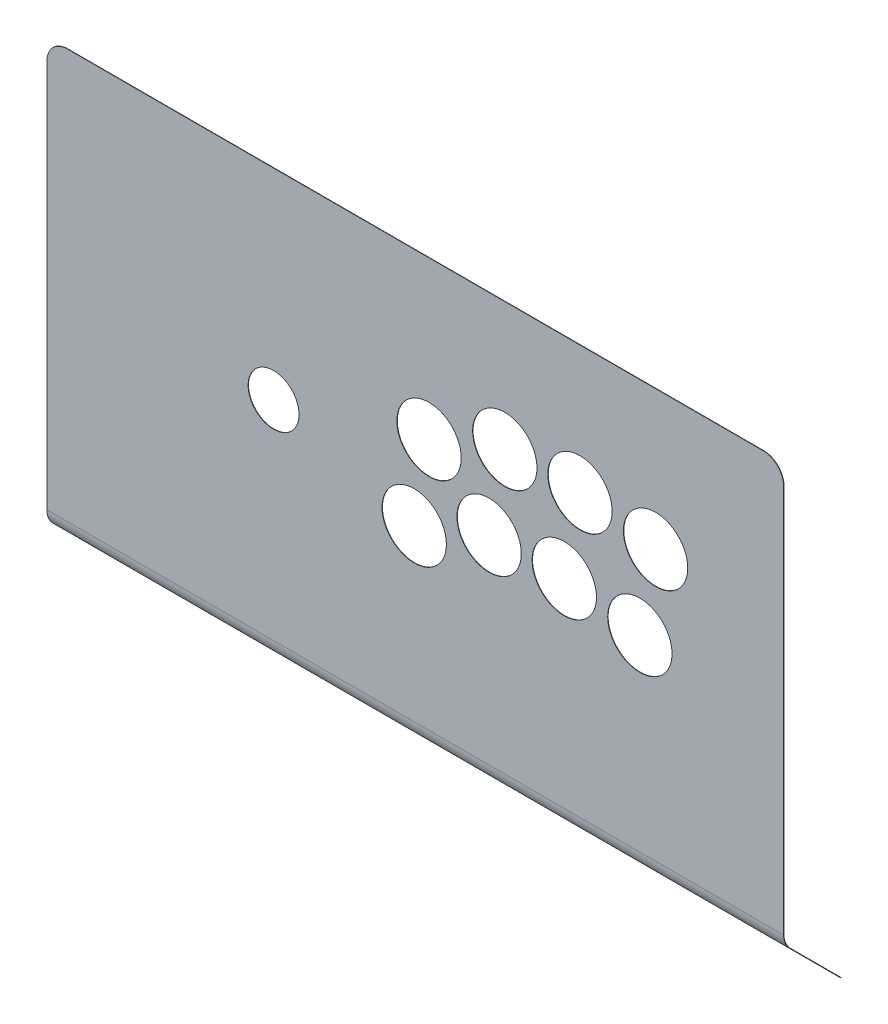
from build123d import *

# Parameters (mm, degrees)
SALIENTE_EXTRUIR1_DEPTH = 180
CORTAR_EXTRUIR1_DEPTH   = 33.901365266
REDONDEO1_R             = 10


with BuildPart() as part:
    # Croquis1 → Saliente-Extruir1 (new body, symmetric)
    with BuildSketch(Plane(origin=(0, 0, 0), x_dir=(0, 0, -1), z_dir=(1, 0, 0))):
        with BuildLine():
            Line((-0.1, 0), (-0.1, -200))
            ThreePointArc((-0.1, -200), (0.668816722, -203.865102667), (2.85822151, -207.14177849))
            Line((2.85822151, -207.14177849), (32.65994391, -236.94350089))
            Line((32.65994391, -236.94350089), (32.801365266, -236.802079534))
            Line((32.801365266, -236.802079534), (2.999642866, -207.000357134))
            ThreePointArc((2.999642866, -207.000357134), (0.853592628, -203.78856598), (0.1, -200))
            Line((0.1, -200), (0.1, 0))
            Line((0.1, 0), (-0.1, 0))
        make_face()
    extrude(amount=SALIENTE_EXTRUIR1_DEPTH, both=True)

    # Croquis3 → Cortar-Extruir1 (cut, through all)
    with BuildSketch(Plane.XY.offset(0.1)):
        with BuildLine():
            add(Edge.make_bspline(
                [(-56.818714387, -98.117897598), (-56.818714387, -91.25310519), (-62.383577946, -85.688592196), (-69.248335297, -85.688592196)],
                knots=[0, 0, 0, 0, 1, 1, 1, 1], degree=3))
            add(Edge.make_bspline(
                [(-69.248335297, -85.688592196), (-76.113123116, -85.688592196), (-81.678337379, -91.25310519), (-81.678337379, -98.117897598)],
                knots=[1, 1, 1, 1, 2, 2, 2, 2], degree=3))
            add(Edge.make_bspline(
                [(-81.678337379, -98.117897598), (-81.678337379, -104.982654949), (-76.113123116, -110.547167943), (-69.248335297, -110.547167943)],
                knots=[2, 2, 2, 2, 3, 3, 3, 3], degree=3))
            add(Edge.make_bspline(
                [(-69.248335297, -110.547167943), (-62.383577946, -110.547167943), (-56.818714387, -104.982654949), (-56.818714387, -98.117897598)],
                knots=[3, 3, 3, 3, 4, 4, 4, 4], degree=3))
        make_face()
        with BuildLine():
            add(Edge.make_bspline(
                [(59.462640026, -62.574601525), (59.462640026, -53.897424834), (52.429085786, -46.863555086), (43.751601027, -46.863555086)],
                knots=[0, 0, 0, 0, 1, 1, 1, 1], degree=3))
            add(Edge.make_bspline(
                [(43.751601027, -46.863555086), (35.074774682, -46.863555086), (28.040196583, -53.897424834), (28.040196583, -62.574601525)],
                knots=[1, 1, 1, 1, 2, 2, 2, 2], degree=3))
            add(Edge.make_bspline(
                [(28.040196583, -62.574601525), (28.040196583, -71.25174316), (35.074774682, -78.285647964), (43.751601027, -78.285647964)],
                knots=[2, 2, 2, 2, 3, 3, 3, 3], degree=3))
            add(Edge.make_bspline(
                [(43.751601027, -78.285647964), (52.429085786, -78.285647964), (59.462640026, -71.25174316), (59.462640026, -62.574601525)],
                knots=[3, 3, 3, 3, 4, 4, 4, 4], degree=3))
        make_face()
        with BuildLine():
            add(Edge.make_bspline(
                [(96.199012837, -62.574601525), (96.199012837, -53.897424834), (89.165108032, -46.863555086), (80.487974766, -46.863555086)],
                knots=[0, 0, 0, 0, 1, 1, 1, 1], degree=3))
            add(Edge.make_bspline(
                [(80.487974766, -46.863555086), (71.811498985, -46.863555086), (64.777235467, -53.897424834), (64.777235467, -62.574601525)],
                knots=[1, 1, 1, 1, 2, 2, 2, 2], degree=3))
            add(Edge.make_bspline(
                [(64.777235467, -62.574601525), (64.777235467, -71.25174316), (71.811498985, -78.285647964), (80.487974766, -78.285647964)],
                knots=[2, 2, 2, 2, 3, 3, 3, 3], degree=3))
            add(Edge.make_bspline(
                [(80.487974766, -78.285647964), (89.165108032, -78.285647964), (96.199012837, -71.25174316), (96.199012837, -62.574601525)],
                knots=[3, 3, 3, 3, 4, 4, 4, 4], degree=3))
        make_face()
        with BuildLine():
            add(Edge.make_bspline(
                [(133.13290348, -68.068616053), (133.13290348, -59.391439362), (126.099033555, -52.357569614), (117.421856645, -52.357569614)],
                knots=[0, 0, 0, 0, 1, 1, 1, 1], degree=3))
            add(Edge.make_bspline(
                [(117.421856645, -52.357569614), (108.744714791, -52.357569614), (101.710809809, -59.391439362), (101.710809809, -68.068616053)],
                knots=[1, 1, 1, 1, 2, 2, 2, 2], degree=3))
            add(Edge.make_bspline(
                [(101.710809809, -68.068616053), (101.710809809, -76.745753799), (108.744714791, -83.779662492), (117.421856645, -83.779662492)],
                knots=[2, 2, 2, 2, 3, 3, 3, 3], degree=3))
            add(Edge.make_bspline(
                [(117.421856645, -83.779662492), (126.099033555, -83.779662492), (133.13290348, -76.745753799), (133.13290348, -68.068616053)],
                knots=[3, 3, 3, 3, 4, 4, 4, 4], degree=3))
        make_face()
        with BuildLine():
            add(Edge.make_bspline(
                [(125.465002278, -108.226079357), (125.465002278, -99.548201536), (118.431097296, -92.514331788), (109.753955442, -92.514331788)],
                knots=[0, 0, 0, 0, 1, 1, 1, 1], degree=3))
            add(Edge.make_bspline(
                [(109.753955442, -92.514331788), (101.076778532, -92.514331788), (94.042908606, -99.548201536), (94.042908606, -108.226079357)],
                knots=[1, 1, 1, 1, 2, 2, 2, 2], degree=3))
            add(Edge.make_bspline(
                [(94.042908606, -108.226079357), (94.042908606, -116.902554918), (101.076778532, -123.936424666), (109.753955442, -123.936424666)],
                knots=[2, 2, 2, 2, 3, 3, 3, 3], degree=3))
            add(Edge.make_bspline(
                [(109.753955442, -123.936424666), (118.431097296, -123.936424666), (125.465002278, -116.902554918), (125.465002278, -108.226079357)],
                knots=[3, 3, 3, 3, 4, 4, 4, 4], degree=3))
        make_face()
        with BuildLine():
            add(Edge.make_bspline(
                [(88.532443974, -102.730697627), (88.532443974, -94.053520936), (81.498223661, -87.019651188), (72.821397535, -87.019651188)],
                knots=[0, 0, 0, 0, 1, 1, 1, 1], degree=3))
            add(Edge.make_bspline(
                [(72.821397535, -87.019651188), (64.143905336, -87.019651188), (57.110000531, -94.053520936), (57.110000531, -102.730697627)],
                knots=[1, 1, 1, 1, 2, 2, 2, 2], degree=3))
            add(Edge.make_bspline(
                [(57.110000531, -102.730697627), (57.110000531, -111.407836338), (64.143905336, -118.441744066), (72.821397535, -118.441744066)],
                knots=[2, 2, 2, 2, 3, 3, 3, 3], degree=3))
            add(Edge.make_bspline(
                [(72.821397535, -118.441744066), (81.498223661, -118.441744066), (88.532443974, -111.407836338), (88.532443974, -102.730697627)],
                knots=[3, 3, 3, 3, 4, 4, 4, 4], degree=3))
        make_face()
        with BuildLine():
            add(Edge.make_bspline(
                [(51.794703961, -102.730697627), (51.794703961, -94.053520936), (44.761184778, -87.019651188), (36.083657522, -87.019651188)],
                knots=[0, 0, 0, 0, 1, 1, 1, 1], degree=3))
            add(Edge.make_bspline(
                [(36.083657522, -87.019651188), (27.406831395, -87.019651188), (20.372260518, -94.053520936), (20.372260518, -102.730697627)],
                knots=[1, 1, 1, 1, 2, 2, 2, 2], degree=3))
            add(Edge.make_bspline(
                [(20.372260518, -102.730697627), (20.372260518, -111.407836338), (27.406831395, -118.441744066), (36.083657522, -118.441744066)],
                knots=[2, 2, 2, 2, 3, 3, 3, 3], degree=3))
            add(Edge.make_bspline(
                [(36.083657522, -118.441744066), (44.761184778, -118.441744066), (51.794703961, -111.407836338), (51.794703961, -102.730697627)],
                knots=[3, 3, 3, 3, 4, 4, 4, 4], degree=3))
        make_face()
        with BuildLine():
            add(Edge.make_bspline(
                [(15.193929476, -117.043586996), (15.193929476, -108.366410305), (8.160024671, -101.332540557), (-0.516450891, -101.332540557)],
                knots=[0, 0, 0, 0, 1, 1, 1, 1], degree=3))
            add(Edge.make_bspline(
                [(-0.516450891, -101.332540557), (-9.194293654, -101.332540557), (-16.228198459, -108.366410305), (-16.228198459, -117.043586996)],
                knots=[1, 1, 1, 1, 2, 2, 2, 2], degree=3))
            add(Edge.make_bspline(
                [(-16.228198459, -117.043586996), (-16.228198459, -125.720062558), (-9.194293654, -132.753932306), (-0.516450891, -132.753932306)],
                knots=[2, 2, 2, 2, 3, 3, 3, 3], degree=3))
            add(Edge.make_bspline(
                [(-0.516450891, -132.753932306), (8.160024671, -132.753932306), (15.193929476, -125.720062558), (15.193929476, -117.043586996)],
                knots=[3, 3, 3, 3, 4, 4, 4, 4], degree=3))
        make_face()
        with BuildLine():
            add(Edge.make_bspline(
                [(22.44553494, -76.886824822), (22.44553494, -68.21034926), (15.4119807, -61.17577419), (6.735154573, -61.17577419)],
                knots=[0, 0, 0, 0, 1, 1, 1, 1], degree=3))
            add(Edge.make_bspline(
                [(6.735154573, -61.17577419), (-1.941987061, -61.17577419), (-8.976207374, -68.21034926), (-8.976207374, -76.886824822)],
                knots=[1, 1, 1, 1, 2, 2, 2, 2], degree=3))
            add(Edge.make_bspline(
                [(-8.976207374, -76.886824822), (-8.976207374, -85.563966456), (-1.941987061, -92.597871261), (6.735154573, -92.597871261)],
                knots=[2, 2, 2, 2, 3, 3, 3, 3], degree=3))
            add(Edge.make_bspline(
                [(6.735154573, -92.597871261), (15.4119807, -92.597871261), (22.44553494, -85.563966456), (22.44553494, -76.886824822)],
                knots=[3, 3, 3, 3, 4, 4, 4, 4], degree=3))
        make_face()
    extrude(amount=-CORTAR_EXTRUIR1_DEPTH, mode=Mode.SUBTRACT)

    # Redondeo1
    redondeo1_edges = [part.edges().sort_by_distance(p)[0] for p in [
        (-180, 0, 0),
        (180, -236.872790212, -32.730654588),
        (180, 0, 0),
        (-180, -236.872790212, -32.730654588),
    ]]
    fillet(redondeo1_edges, radius=REDONDEO1_R)


solid = part.part
